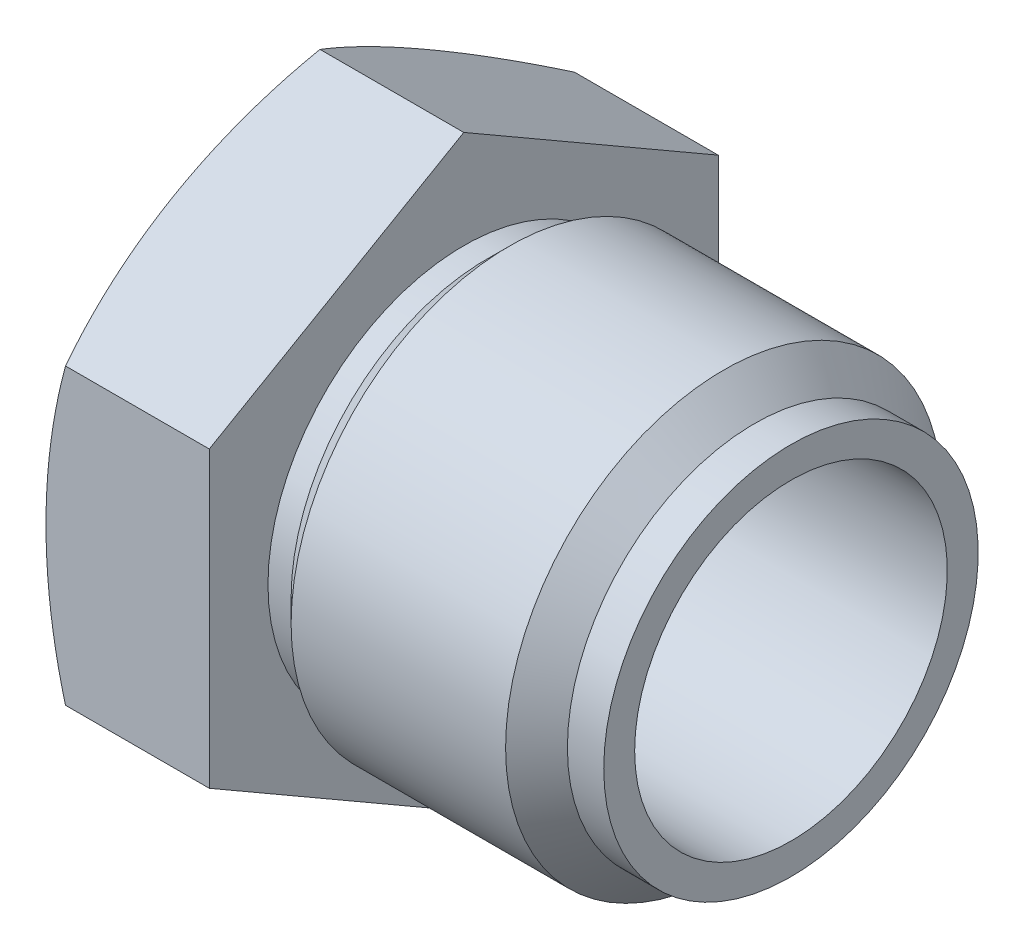
from build123d import *

# Parameters (mm, degrees)
SKETCH2_W          = 10.6
SKETCH2_H          = 4.3
SKETCH3_W          = 40
SKETCH3_H          = 40
CUT_EXTRUDE1_DEPTH = 6.5
CUT_EXTRUDE2_DEPTH = 2.29
SKETCH5_W          = 1.9
SKETCH5_H          = 10.8
CUT_EXTRUDE3_DEPTH = 1.4


with BuildPart() as part:
    # Sketch1 → Revolve1 (revolve)
    with BuildSketch(Plane.XY):
        with BuildLine():
            Line((-2.490737563, 10), (0, 10))
            Line((0, 10), (0, 5.3865))
            Line((0, 5.3865), (0.6365, 5.3865))
            Line((0.6365, 5.3865), (1.25, 6))
            Line((1.25, 6), (7.15, 6))
            Line((7.15, 6), (8, 5.15))
            Line((8, 5.15), (9, 5.15))
            Line((9, 5.15), (9, 0))
            Line((9, 0), (-6, 0))
            ThreePointArc((-6, 0), (-5.206361598, 5.133599494), (-2.899547792, 9.787878788))
            ThreePointArc((-2.899547792, 9.787878788), (-2.721020656, 9.943812682), (-2.490737563, 10))
        make_face()
    revolve(axis=Axis((9, 0, 0), (-1, 0, 0)))

    # Sketch2 → Cut-Revolve1 (revolve, cut)
    with BuildSketch(Plane.XY):
        with Locations((3.7, 2.15)):
            Rectangle(SKETCH2_W, SKETCH2_H)
    revolve(axis=Axis((9, 0, 0), (-1, 0, 0)), mode=Mode.SUBTRACT)

    # Sketch3 → Cut-Extrude1 (cut)
    with BuildSketch(Plane(origin=(-6, 0, 0), x_dir=(0, 0, -1), z_dir=(1, 0, 0))):
        Rectangle(SKETCH3_W, SKETCH3_H)
        Polygon((-7, -4.041451884), (0, -8.082903769), (7, -4.041451884), (7, 4.041451884), (0, 8.082903769), (-7, 4.041451884), align=None, mode=Mode.SUBTRACT)
    extrude(amount=CUT_EXTRUDE1_DEPTH, mode=Mode.SUBTRACT)

    # Sketch4 → Cut-Extrude2 (cut)
    with BuildSketch(Plane(origin=(-6, 0, 0), x_dir=(0, 0, -1), z_dir=(1, 0, 0))):
        with BuildLine():
            Line((-2.189430305, -0.450302912), (-1.45357474, -0.841564257))
            Line((-1.45357474, -0.841564257), (-0.852063671, -0.852063671))
            Line((-0.852063671, -0.852063671), (-0.841564257, -1.45357474))
            Line((-0.841564257, -1.45357474), (-0.450302912, -2.189430305))
            ThreePointArc((-0.450302912, -2.189430305), (0, -2.459999131), (0.450302912, -2.189430305))
            Line((0.450302912, -2.189430305), (0.841564257, -1.45357474))
            Line((0.841564257, -1.45357474), (0.852063671, -0.852063671))
            Line((0.852063671, -0.852063671), (1.45357474, -0.841564257))
            Line((1.45357474, -0.841564257), (2.189430305, -0.450302912))
            ThreePointArc((2.189430305, -0.450302912), (2.459999131, 0), (2.189430305, 0.450302912))
            Line((2.189430305, 0.450302912), (1.45357474, 0.841564257))
            Line((1.45357474, 0.841564257), (0.852063671, 0.852063671))
            Line((0.852063671, 0.852063671), (0.841564257, 1.45357474))
            Line((0.841564257, 1.45357474), (0.450302912, 2.189430305))
            ThreePointArc((0.450302912, 2.189430305), (0, 2.459999131), (-0.450302912, 2.189430305))
            Line((-0.450302912, 2.189430305), (-0.841564257, 1.45357474))
            Line((-0.841564257, 1.45357474), (-0.852063671, 0.852063671))
            Line((-0.852063671, 0.852063671), (-1.45357474, 0.841564257))
            Line((-1.45357474, 0.841564257), (-2.189430305, 0.450302912))
            ThreePointArc((-2.189430305, 0.450302912), (-2.459999131, 0), (-2.189430305, -0.450302912))
        make_face()
    extrude(amount=CUT_EXTRUDE2_DEPTH, mode=Mode.SUBTRACT)

    # Sketch5 → Cut-Extrude3 (cut)
    with BuildSketch(Plane(origin=(-6, 0, 0), x_dir=(0, 0, -1), z_dir=(1, 0, 0))):
        Rectangle(SKETCH5_W, SKETCH5_H)
    extrude(amount=CUT_EXTRUDE3_DEPTH, mode=Mode.SUBTRACT)


solid = part.part
